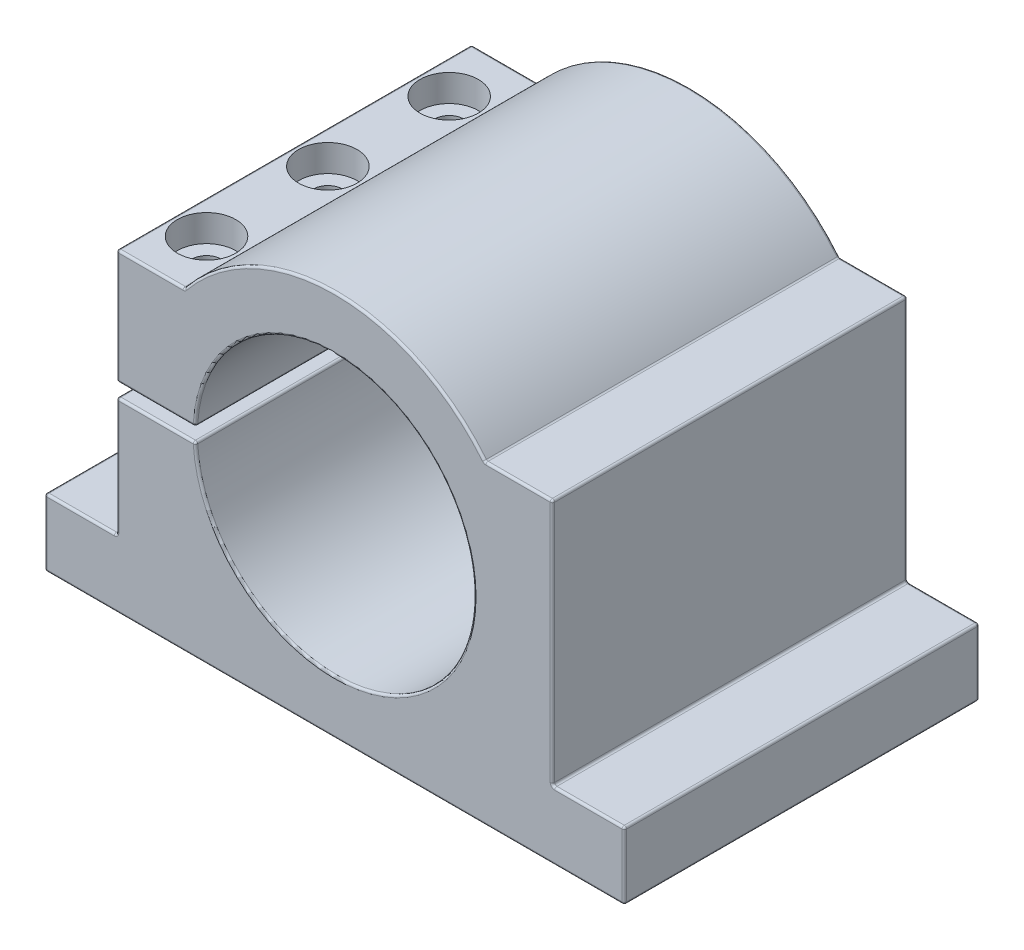
from build123d import *

# Parameters (mm, degrees)
EXTRUDE_1_DEPTH     = 39.5
SKETCH_2_R          = 6.5
CUT_EXTRUDE_1_DEPTH = 6
SKETCH_3_R          = 3.25
CUT_EXTRUDE_2_DEPTH = 22.5
SKETCH_4_R          = 2.6
CUT_EXTRUDE_3_DEPTH = 30
FILLET_1_R          = 0.5


with BuildPart() as part:
    # Эскиз1 → Бобышка-Вытянуть1 (new body, symmetric)
    with BuildSketch(Plane.XY):
        with BuildLine():
            Line((64.5, -43), (64.5, -28))
            Line((64.5, -28), (48.5, -28))
            Line((48.5, -28), (48.5, 27))
            Line((48.5, 27), (33.466401061, 27))
            ThreePointArc((33.466401061, 27), (0, 43), (-33.466401061, 27))
            Line((-33.466401061, 27), (-48.5, 27))
            Line((-48.5, 27), (-48.5, 1.5))
            Line((-48.5, 1.5), (-30.963688411, 1.5))
            ThreePointArc((-30.963688411, 1.5), (31, 0), (-30.963688411, -1.5))
            Line((-30.963688411, -1.5), (-48.5, -1.5))
            Line((-48.5, -1.5), (-48.5, -28))
            Line((-48.5, -28), (-64.5, -28))
            Line((-64.5, -28), (-64.5, -43))
            Line((-64.5, -43), (64.5, -43))
        make_face()
    extrude(amount=EXTRUDE_1_DEPTH, both=True)

    # Эскиз2 → Вырез-Вытянуть1 (cut)
    with BuildSketch(Plane(origin=(0, 27, 0), x_dir=(1, 0, 0), z_dir=(0, 1, 0))):
        with Locations((-40.983200531, 27)):
            Circle(SKETCH_2_R)
        with Locations((-40.983200531, 0)):
            Circle(SKETCH_2_R)
        with Locations((-40.983200531, -27)):
            Circle(SKETCH_2_R)
    extrude(amount=-CUT_EXTRUDE_1_DEPTH, mode=Mode.SUBTRACT)

    # Эскиз3 → Вырез-Вытянуть2 (cut)
    with BuildSketch(Plane(origin=(0, 21, 0), x_dir=(1, 0, 0), z_dir=(0, 1, 0))):
        with Locations((-40.983200531, 27)):
            Circle(SKETCH_3_R)
        with Locations((-40.983200531, 0)):
            Circle(SKETCH_3_R)
        with Locations((-40.983200531, -27)):
            Circle(SKETCH_3_R)
    extrude(amount=-CUT_EXTRUDE_2_DEPTH, mode=Mode.SUBTRACT)

    # Эскиз4 → Вырез-Вытянуть3 (cut)
    with BuildSketch(Plane(origin=(0, -1.5, 0), x_dir=(1, 0, 0), z_dir=(0, 1, 0))):
        with Locations((-40.983200531, 27)):
            Circle(SKETCH_4_R)
        with Locations((-40.983200531, 0)):
            Circle(SKETCH_4_R)
        with Locations((-40.983200531, -27)):
            Circle(SKETCH_4_R)
    extrude(amount=-CUT_EXTRUDE_3_DEPTH, mode=Mode.SUBTRACT)

    # Скругление1
    fillet_1_edges = [part.edges().sort_by_distance(p)[0] for p in [
        (56.5, -28, 39.5),
        (-64.5, -35.5, -39.5),
        (-56.5, -28, -39.5),
        (-48.5, -14.75, -39.5),
        (-39.731844205, -1.5, -39.5),
        (31, 0, -39.5),
        (48.5, -0.5, 39.5),
        (-39.731844205, 1.5, -39.5),
        (-48.5, 14.25, -39.5),
        (-40.983200531, 27, -39.5),
        (0, 43, -39.5),
        (40.983200531, 27, -39.5),
        (48.5, -0.5, -39.5),
        (56.5, -28, -39.5),
        (64.5, -35.5, -39.5),
        (40.983200531, 27, 39.5),
        (0, -43, -39.5),
        (0, 43, 39.5),
        (-64.5, -43, 0),
        (-64.5, -28, 0),
        (-48.5, -28, 0),
        (-48.5, -1.5, 0),
        (-30.963688411, -1.5, 0),
        (-30.963688411, 1.5, 0),
        (-48.5, 1.5, 0),
        (-48.5, 27, 0),
        (-33.466401061, 27, 0),
        (33.466401061, 27, 0),
        (48.5, 27, 0),
        (48.5, -28, 0),
        (64.5, -28, 0),
        (64.5, -43, 0),
        (-40.983200531, 27, 39.5),
        (-48.5, 14.25, 39.5),
        (-39.731844205, 1.5, 39.5),
        (0, -43, 39.5),
        (31, 0, 39.5),
        (-39.731844205, -1.5, 39.5),
        (-48.5, -14.75, 39.5),
        (-56.5, -28, 39.5),
        (-64.5, -35.5, 39.5),
        (64.5, -35.5, 39.5),
    ]]
    fillet(fillet_1_edges, radius=FILLET_1_R)


solid = part.part
